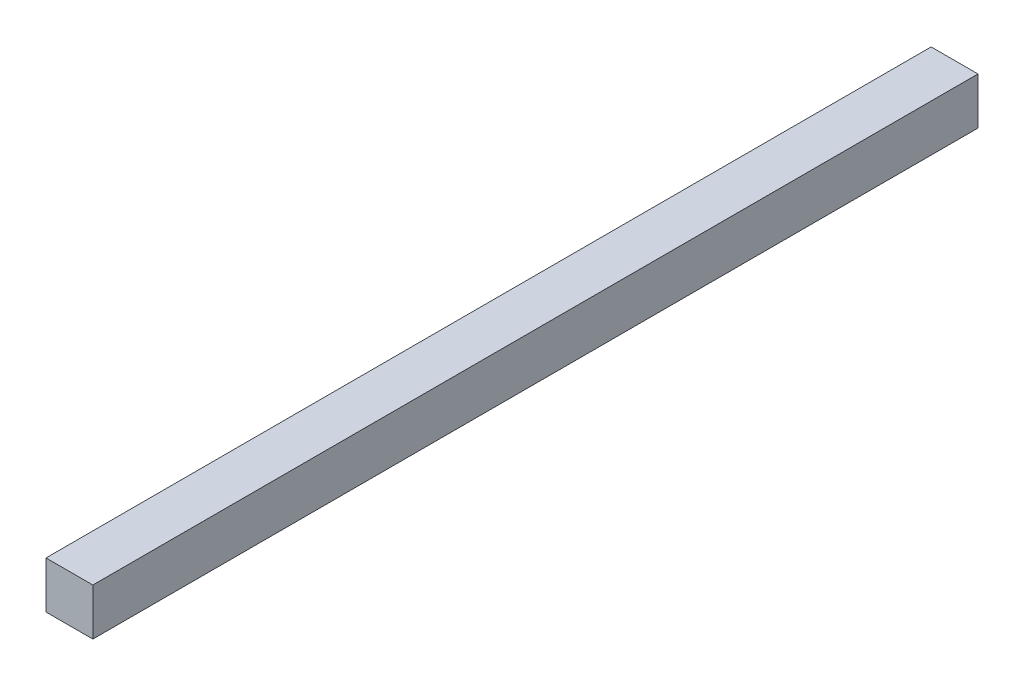
from build123d import *

# Parameters (mm, degrees)
ESQUISSE1_W      = 18
ESQUISSE1_H      = 18
EXTRUSION1_DEPTH = 340


with BuildPart() as part:
    # Esquisse1 → Extrusion1 (new body)
    with BuildSketch(Plane.XY):
        with Locations((9, 9)):
            Rectangle(ESQUISSE1_W, ESQUISSE1_H)
    extrude(amount=-EXTRUSION1_DEPTH)


solid = part.part
